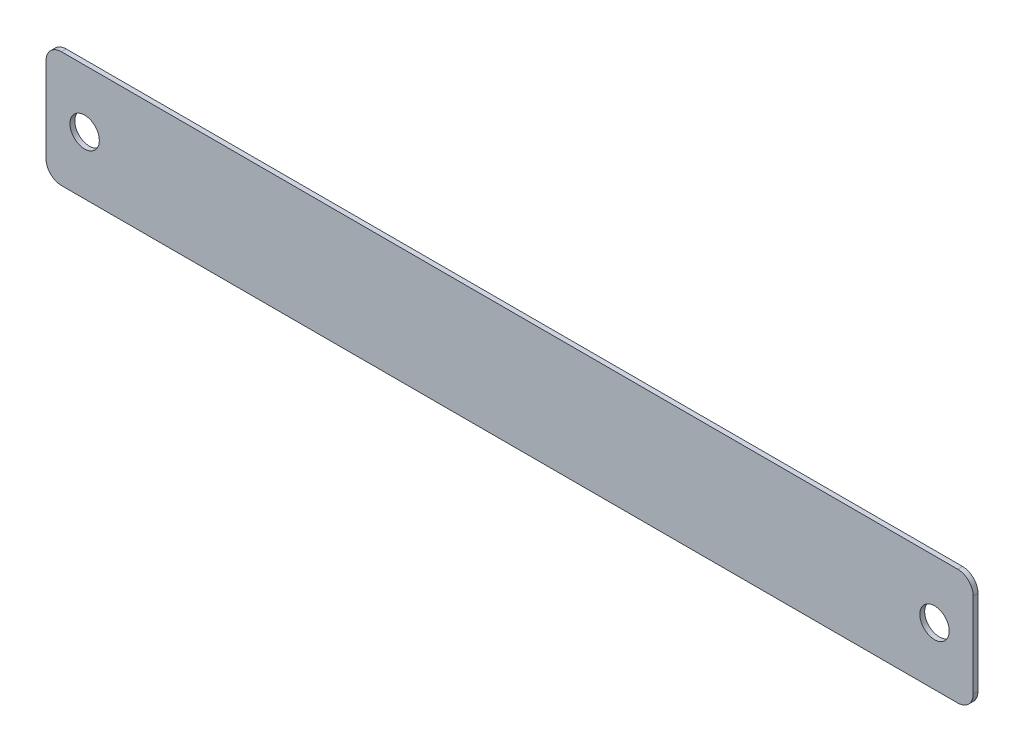
from build123d import *

# Parameters (mm, degrees)
SKETCH1_W           = 152.4
SKETCH1_H           = 19.05
SKETCH1_R           = 2.413
BOSS_EXTRUDE1_DEPTH = 0.79375
FILLET1_R           = 2.54


with BuildPart() as part:
    # Sketch1 → Boss-Extrude1 (new body)
    with BuildSketch(Plane.XY):
        with Locations((76.2, 9.525)):
            Rectangle(SKETCH1_W, SKETCH1_H)
        with Locations((6.35, 9.525)):
            Circle(SKETCH1_R, mode=Mode.SUBTRACT)
        with Locations((146.05, 9.525)):
            Circle(SKETCH1_R, mode=Mode.SUBTRACT)
    extrude(amount=BOSS_EXTRUDE1_DEPTH)

    # Fillet1
    fillet1_edges = [part.edges().sort_by_distance(p)[0] for p in [
        (0, 19.05, 0.396875),
        (152.4, 19.05, 0.396875),
        (152.4, 0, 0.396875),
        (0, 0, 0.396875),
    ]]
    fillet(fillet1_edges, radius=FILLET1_R)


solid = part.part
